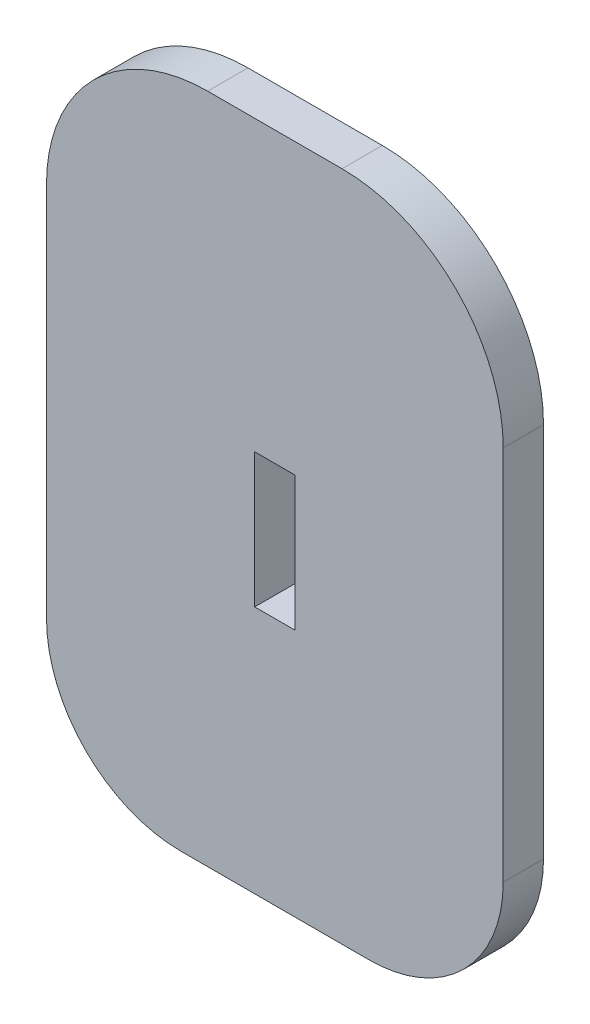
from build123d import *

# Parameters (mm, degrees)
BOSS_EXTRUDE1_DEPTH = 3
SKETCH2_W           = 3
SKETCH2_H           = 10
CUT_EXTRUDE1_DEPTH  = 10


with BuildPart() as part:
    # Sketch1 → Boss-Extrude1 (new body)
    with BuildSketch(Plane.XY):
        with BuildLine():
            Line((-5, -21.5), (5, -21.5))
            ThreePointArc((5, -21.5), (13.485281374, -25.014718626), (17, -33.5))
            Line((17, -33.5), (17, -61.5))
            ThreePointArc((17, -61.5), (14.071067812, -68.571067812), (7, -71.5))
            Line((7, -71.5), (0.5, -71.5))
            Line((0.5, -71.5), (-0.5, -71.5))
            Line((-0.5, -71.5), (-7, -71.5))
            ThreePointArc((-7, -71.5), (-14.071067812, -68.571067812), (-17, -61.5))
            Line((-17, -61.5), (-17, -33.5))
            ThreePointArc((-17, -33.5), (-13.485281374, -25.014718626), (-5, -21.5))
        make_face()
    extrude(amount=BOSS_EXTRUDE1_DEPTH)

    # Sketch2 → Cut-Extrude1 (cut)
    with BuildSketch(Plane.XY.offset(3)):
        with Locations((0, -48)):
            Rectangle(SKETCH2_W, SKETCH2_H)
    extrude(amount=-CUT_EXTRUDE1_DEPTH, mode=Mode.SUBTRACT)


solid = part.part
